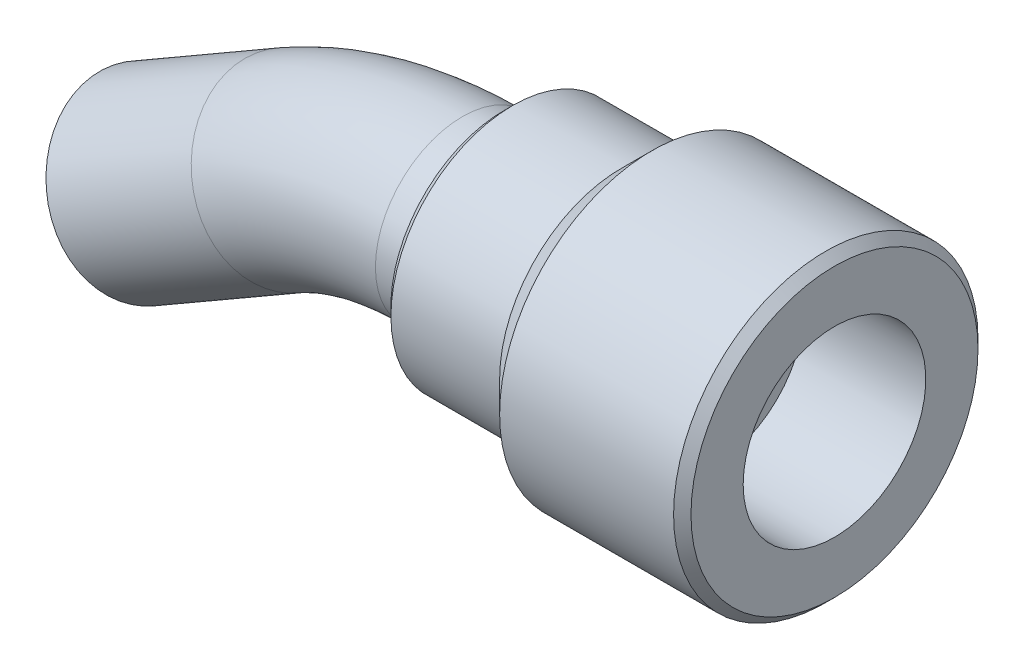
from build123d import *

# Parameters (mm, degrees)
CHAMFER1_SIZE = 1
SKETCH2_R     = 10
SKETCH2_R_2   = 6


with BuildPart() as part:
    # Sketch1 → Revolve1 (revolve)
    with BuildSketch(Plane.XY):
        Polygon((0, 10), (0, 14), (13.5, 14), (17, 17.5), (38, 17.5), (38, 10.5), (24, 10.5), (24, 6), (14.5, 6), (14.5, 10), align=None)
    revolve(axis=Axis((0, 0, 0), (1, 0, 0)))

    # Chamfer1
    chamfer1_edges = [part.edges().sort_by_distance(p)[0] for p in [
        (38, -17.5, 0),
        (0, -14, 0),
    ]]
    chamfer(chamfer1_edges, length=CHAMFER1_SIZE)

    # Sweep6: sweep along a path in Sketch3
    with BuildLine(Plane.XY) as sweep6_path:
        Line((14.5, 0), (-4.782032303, 0))
        ThreePointArc((-4.782032303, 0), (-15.134794107, -1.362966948), (-24.782032303, -5.358983849))
        Line((-24.782032303, -5.358983849), (-41.480762114, -15))
    # Sketch2 → Sweep6 (sweep)
    with BuildSketch(Plane.ZY.offset(-14.5)):
        Circle(SKETCH2_R)
        Circle(SKETCH2_R_2, mode=Mode.SUBTRACT)
    sweep(path=sweep6_path.line)


solid = part.part
